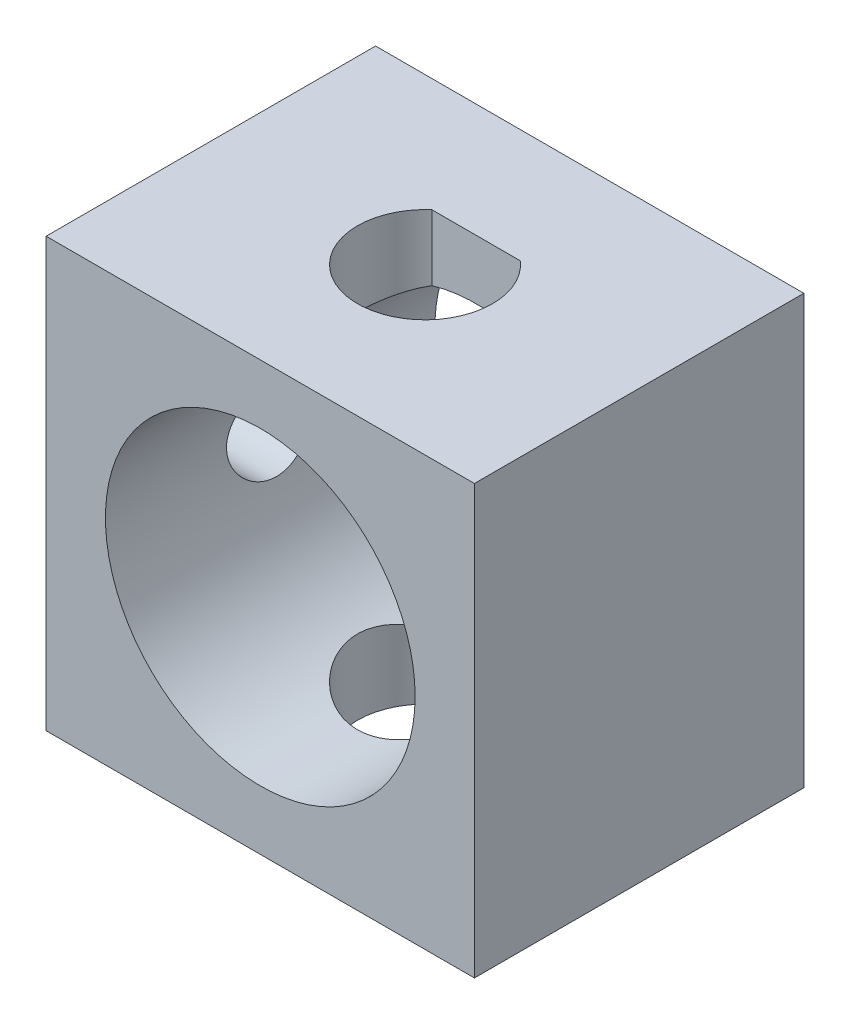
from build123d import *

# Parameters (mm, degrees)
SKETCH1_W           = 13
SKETCH1_H           = 10
BOSS_EXTRUDE1_DEPTH = 13
SKETCH2_R           = 4.7
CUT_EXTRUDE1_DEPTH  = 10
CUT_EXTRUDE2_REACH  = 15
SKETCH3_R           = 1.325


with BuildPart() as part:
    # Sketch1 → Boss-Extrude1 (new body)
    with BuildSketch(Plane(origin=(0, 0, 0), x_dir=(1, 0, 0), z_dir=(0, 1, 0))):
        Rectangle(SKETCH1_W, SKETCH1_H)
        with BuildLine():
            Line((-1.341640786, 1.55), (1.341640786, 1.55))
            ThreePointArc((1.341640786, 1.55), (0, -2.05), (-1.341640786, 1.55))
        make_face(mode=Mode.SUBTRACT)
    extrude(amount=BOSS_EXTRUDE1_DEPTH)

    # Sketch2 → Cut-Extrude1 (cut)
    with BuildSketch(Plane.XY.offset(5)):
        with Locations((0, 6.5)):
            Circle(SKETCH2_R)
    extrude(amount=-CUT_EXTRUDE1_DEPTH, mode=Mode.SUBTRACT)

    # Sketch3 → Cut-Extrude2 (cut, up to next)
    with BuildSketch(Plane.ZY.offset(6.5), mode=Mode.PRIVATE) as cut_extrude2_sk1:
        with Locations((0, 6.5)):
            Circle(SKETCH3_R)
    cut_extrude2_tool1 = extrude(cut_extrude2_sk1.sketch, amount=-CUT_EXTRUDE2_REACH, mode=Mode.PRIVATE) & part.part
    add(cut_extrude2_tool1.solids().sort_by_distance((-6.5, 6.5, 0))[0], mode=Mode.SUBTRACT)


solid = part.part
